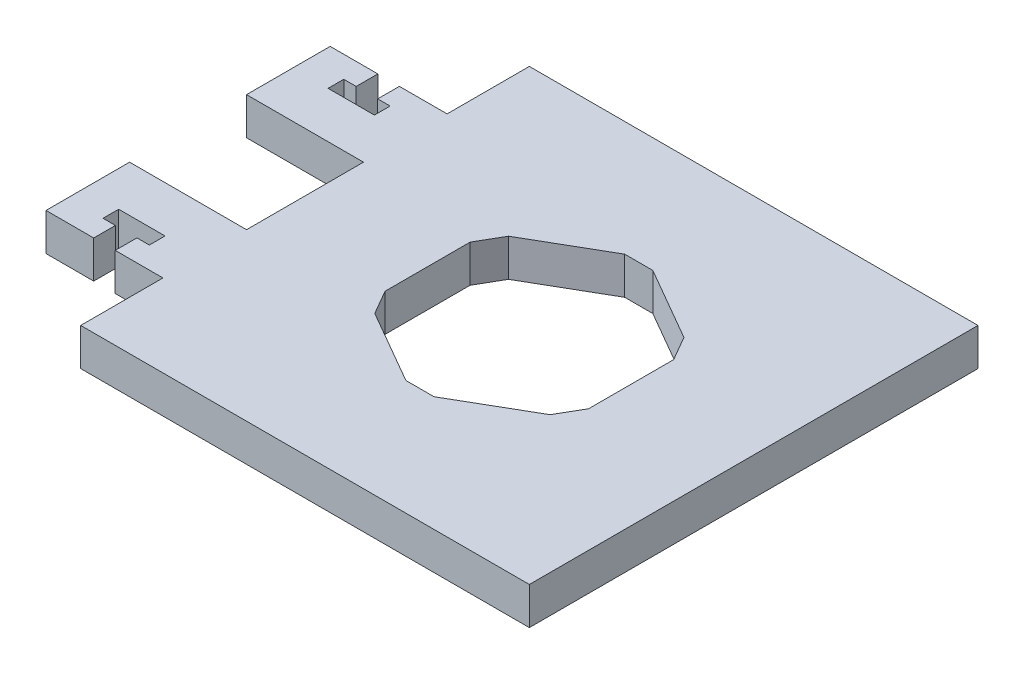
from build123d import *

# Parameters (mm, degrees)
BOSS_EXTRUDE1_DEPTH = 6.35


with BuildPart() as part:
    # Sketch1 → Boss-Extrude1 (new body)
    with BuildSketch(Plane(origin=(0, 0, 0), x_dir=(1, 0, 0), z_dir=(0, 1, 0))):
        Polygon((-38.1, -38.1), (38.1, -38.1), (38.1, 38.1), (-38.1, 38.1), (-38.1, 24.13), (-46.2026, 24.13), (-46.2026, 20.447), (-44.0944, 20.447), (-44.0944, 17.78), (-51.9684, 17.78), (-51.9684, 20.447), (-49.8602, 20.447), (-49.8602, 24.13), (-57.9628, 24.13), (-57.9628, 9.9314), (-38.1, 9.9314), (-38.1, -9.9314), (-57.9628, -9.9314), (-57.9628, -24.13), (-49.8602, -24.13), (-49.8602, -20.447), (-51.9684, -20.447), (-51.9684, -17.78), (-44.0944, -17.78), (-44.0944, -20.447), (-46.2026, -20.447), (-46.2026, -24.13), (-38.1, -24.13), align=None)
        Polygon((-2.389310714, -18.580574179), (2.389310714, -18.580574179), (14.896593899, -11.359490865), (17.285904613, -7.221083314), (17.285904613, 7.221083314), (14.896593899, 11.359490865), (2.389310714, 18.580574179), (-2.389310714, 18.580574179), (-14.896593899, 11.359490865), (-17.285904613, 7.221083314), (-17.285904613, -7.221083314), (-14.896593899, -11.359490865), align=None, mode=Mode.SUBTRACT)
    extrude(amount=-BOSS_EXTRUDE1_DEPTH)


solid = part.part
